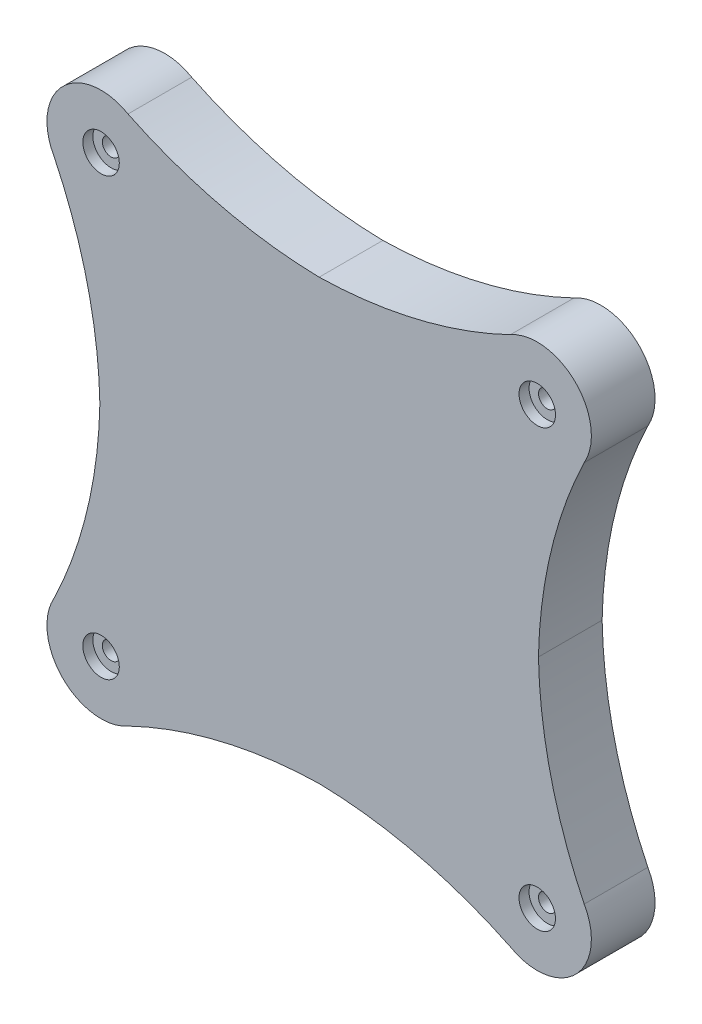
from build123d import *

# Parameters (mm, degrees)
SKETCH1_R                               = 87.47125
BOSS_EXTRUDE1_DEPTH                     = 25.4
BOSS_EXTRUDE2_DEPTH                     = 25.4
CUT_EXTRUDE1_REACH                      = 31.21
CUT_EXTRUDE1_START                      = -3.81
SKETCH8_R                               = 72.38365
CBORE_FOR_M6_HEX_HEAD_BOLT1_D           = 7
CBORE_FOR_M6_HEX_HEAD_BOLT1_CBORE_D     = 14.547
CBORE_FOR_M6_HEX_HEAD_BOLT1_CBORE_DEPTH = 4


with BuildPart() as part:
    # Sketch1 → Boss-Extrude1 (new body)
    with BuildSketch(Plane.XY):
        Circle(SKETCH1_R)
    extrude(amount=BOSS_EXTRUDE1_DEPTH)

    # Sketch3 → Boss-Extrude2 (add)
    with BuildSketch(Plane.XY):
        with BuildLine():
            ThreePointArc((-76.246005737, 105.719498865), (-102.262666579, 102.262666579), (-105.719498865, 76.246005737))
            ThreePointArc((-105.719498865, 76.246005737), (-92.490752346, 39.105377809), (-87.47125, 0))
            ThreePointArc((-87.47125, 0), (-92.490752346, -39.105377809), (-105.719498865, -76.246005737))
            ThreePointArc((-105.719498865, -76.246005737), (-102.262666579, -102.262666579), (-76.246005737, -105.719498865))
            ThreePointArc((-76.246005737, -105.719498865), (-39.105377809, -92.490752346), (0, -87.47125))
            ThreePointArc((0, -87.47125), (39.105377809, -92.490752346), (76.246005737, -105.719498865))
            ThreePointArc((76.246005737, -105.719498865), (102.262666579, -102.262666579), (105.719498865, -76.246005737))
            ThreePointArc((105.719498865, -76.246005737), (92.490752346, -39.105377809), (87.47125, 0))
            ThreePointArc((87.47125, 0), (92.490752346, 39.105377809), (105.719498865, 76.246005737))
            ThreePointArc((105.719498865, 76.246005737), (102.262666579, 102.262666579), (76.246005737, 105.719498865))
            ThreePointArc((76.246005737, 105.719498865), (39.105377809, 92.490752346), (0, 87.47125))
            ThreePointArc((0, 87.47125), (-39.105377809, 92.490752346), (-76.246005737, 105.719498865))
        make_face()
    extrude(amount=BOSS_EXTRUDE2_DEPTH)

    # Sketch8 → Cut-Extrude1 (cut, up to next)
    with BuildSketch(Plane.XY.offset(25.4).offset(CUT_EXTRUDE1_START), mode=Mode.PRIVATE) as cut_extrude1_sk1:
        Circle(SKETCH8_R)
    cut_extrude1_tool1 = extrude(cut_extrude1_sk1.sketch, amount=-CUT_EXTRUDE1_REACH, mode=Mode.PRIVATE) & part.part
    add(cut_extrude1_tool1.solids().sort_by_distance((0, 0, 21.59))[0], mode=Mode.SUBTRACT)

    # CBORE for M6 Hex Head Bolt1 (through all)
    with Locations(Plane.XY.offset(25.4)):
        with Locations((-86.996231173, 86.996231173), (86.996231173, 86.996231173), (86.996231173, -86.996231173), (-86.996231173, -86.996231173)):
            CounterBoreHole(CBORE_FOR_M6_HEX_HEAD_BOLT1_D / 2, CBORE_FOR_M6_HEX_HEAD_BOLT1_CBORE_D / 2, CBORE_FOR_M6_HEX_HEAD_BOLT1_CBORE_DEPTH)


solid = part.part
